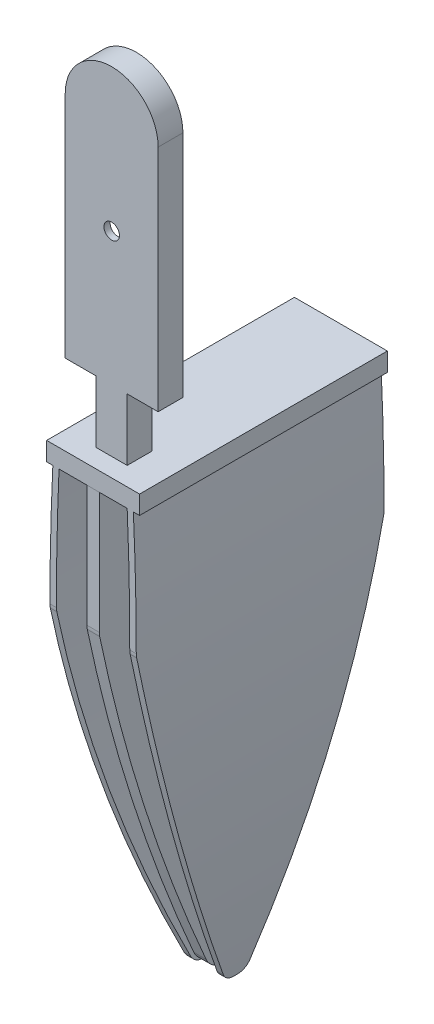
from build123d import *

# Parameters (mm, degrees)
EXTRUDE_1_DEPTH          = 2
EXTRUDE_1_DEPTH_BACK     = 2
EXTRUDE_2_DEPTH          = 7.5
EXTRUDE_2_DEPTH_BACK     = 7.5
EXTRUDE_4_DEPTH          = 1
EXTRUDE_4_DEPTH_BACK     = 1
EXTRUDE_8_DEPTH          = 23
EXTRUDE_8_DEPTH_BACK     = 17
SKETCH_21_W              = 5
SKETCH_21_H              = 10
CUT_EXTRUDE_4_DEPTH      = 4
CUT_EXTRUDE_5_DEPTH      = 1
CUT_EXTRUDE_5_DEPTH_BACK = 2
SKETCH_23_R              = 1.25
CUT_EXTRUDE_6_DEPTH      = 13
FILLET_11_R              = 3
FILLET_12_R              = 3
FILLET_13_R              = 3
CUT_EXTRUDE_7_DEPTH      = 10
CUT_EXTRUDE_7_DEPTH_BACK = 10
FILLET_17_R              = 2
FILLET_18_R              = 2
FILLET_19_R              = 2
FILLET_20_R              = 2
FILLET_21_R              = 3
FILLET_22_R              = 3
FILLET_23_R              = 3
FILLET_24_R              = 3


with BuildPart() as part:
    # 草圖1 → 填料-伸長1 (new, two sides: drawn at the far end of the back side and taken through both)
    with BuildSketch(Plane.XY.offset(-EXTRUDE_1_DEPTH_BACK)):
        with BuildLine():
            Line((7.5, 8), (7.5, 55))
            ThreePointArc((7.5, 55), (0, 62.5), (-7.5, 55))
            Line((-7.5, 55), (-7.5, 8))
            Line((-7.5, 8), (7.5, 8))
        make_face()
    extrude(amount=EXTRUDE_1_DEPTH + EXTRUDE_1_DEPTH_BACK)

    # 草圖6 → 填料-伸長2 (add, two sides: drawn at the far end of the back side and taken through both)
    with BuildSketch(Plane(origin=(0, 0, 0), x_dir=(0, 0, -1), z_dir=(1, 0, 0)).offset(-EXTRUDE_2_DEPTH_BACK)):
        Polygon((-2, 8), (-5, 8), (-5, 5), (-2, 5), (35, 5), (35, 8), align=None)
    extrude(amount=EXTRUDE_2_DEPTH + EXTRUDE_2_DEPTH_BACK)

    # 草圖19 → 填料-伸長8 (add, two sides: drawn at the far end of the back side and taken through both)
    with BuildSketch(Plane.XY.offset(-18).offset(-EXTRUDE_8_DEPTH_BACK)):
        with BuildLine():
            Line((6.5, 5), (5.5, 5))
            ThreePointArc((5.5, 5), (5.47282517, -33.328822067), (2, -71.5))
            Line((2, -71.5), (3, -71.5))
            ThreePointArc((3, -71.5), (6.537897336, -33.331799225), (6.5, 5))
        make_face()
        with BuildLine():
            Line((-3, -71.5), (-2, -71.5))
            ThreePointArc((-2, -71.5), (-5.47282517, -33.328822067), (-5.5, 5))
            Line((-5.5, 5), (-6.5, 5))
            ThreePointArc((-6.5, 5), (-6.537897336, -33.331799225), (-3, -71.5))
        make_face()
    extrude(amount=EXTRUDE_8_DEPTH + EXTRUDE_8_DEPTH_BACK)

    # 草圖21 → 除料-伸長4 (cut)
    with BuildSketch(Plane.XY.offset(2)):
        with Locations((-5, 13)):
            Rectangle(SKETCH_21_W, SKETCH_21_H)
        with Locations((5, 13)):
            Rectangle(SKETCH_21_W, SKETCH_21_H)
    extrude(amount=-CUT_EXTRUDE_4_DEPTH, mode=Mode.SUBTRACT)

    # 草圖3 → 除料-伸長5 (cut, two sides: drawn at the far end of the back side and taken through both)
    with BuildSketch(Plane.XY.offset(-CUT_EXTRUDE_5_DEPTH_BACK)):
        with BuildLine():
            Line((-2.106194146, 57.35480611), (-4.932538983, 40.323847539))
            ThreePointArc((-4.932538983, 40.323847539), (-5, 39.50527611), (-4.932538983, 38.686704682))
            Line((-4.932538983, 38.686704682), (-2.106194146, 21.65574611))
            ThreePointArc((-2.106194146, 21.65574611), (0, 19.87027611), (2.106194146, 21.65574611))
            Line((2.106194146, 21.65574611), (4.932538983, 38.686704682))
            ThreePointArc((4.932538983, 38.686704682), (5, 39.50527611), (4.932538983, 40.323847539))
            Line((4.932538983, 40.323847539), (2.106194146, 57.35480611))
            ThreePointArc((2.106194146, 57.35480611), (0, 59.14027611), (-2.106194146, 57.35480611))
        make_face()
    extrude(amount=CUT_EXTRUDE_5_DEPTH + CUT_EXTRUDE_5_DEPTH_BACK, mode=Mode.SUBTRACT)

    # 草圖23 → 除料-伸長6 (cut)
    with BuildSketch(Plane(origin=(0, 0, -2), x_dir=(-1, 0, 0), z_dir=(0, 0, -1))):
        with Locations((0, 39.50527611)):
            Circle(SKETCH_23_R)
    extrude(amount=-CUT_EXTRUDE_6_DEPTH, mode=Mode.SUBTRACT)

    # 草圖20 → 除料-伸長7 (cut, two sides: drawn at the far end of the back side and taken through both)
    with BuildSketch(Plane(origin=(0, 0, 0), x_dir=(0, 0, -1), z_dir=(1, 0, 0)).offset(-CUT_EXTRUDE_7_DEPTH_BACK)):
        with BuildLine():
            ThreePointArc((15, -75), (3.242716215, -45.534786617), (-5, -14.9))
            Line((-5, -14.9), (-5, -75))
            Line((-5, -75), (15, -75))
        make_face()
        with BuildLine():
            ThreePointArc((35, -14.9), (26.757283785, -45.534786617), (15, -75))
            Line((15, -75), (35, -75))
            Line((35, -75), (35, -14.9))
        make_face()
    extrude(amount=CUT_EXTRUDE_7_DEPTH + CUT_EXTRUDE_7_DEPTH_BACK, mode=Mode.SUBTRACT)

    # 圓角17
    fillet_17_edges = [part.edges().sort_by_distance(p)[0] for p in [
        (2.5, -71.5, -16.609354803),
    ]]
    fillet(fillet_17_edges, radius=FILLET_17_R)

    # 圓角18
    fillet_18_edges = [part.edges().sort_by_distance(p)[0] for p in [
        (2.5, -71.5, -13.390645197),
    ]]
    fillet(fillet_18_edges, radius=FILLET_18_R)

    # 圓角19
    fillet_19_edges = [part.edges().sort_by_distance(p)[0] for p in [
        (-2.5, -71.5, -16.609354803),
    ]]
    fillet(fillet_19_edges, radius=FILLET_19_R)

    # 圓角20
    fillet_20_edges = [part.edges().sort_by_distance(p)[0] for p in [
        (-2.5, -71.5, -13.390645197),
    ]]
    fillet(fillet_20_edges, radius=FILLET_20_R)

    # 圓角21
    fillet_21_edges = [part.edges().sort_by_distance(p)[0] for p in [
        (-6.441667624, -14.9, 5),
    ]]
    fillet(fillet_21_edges, radius=FILLET_21_R)

    # 圓角22
    fillet_22_edges = [part.edges().sort_by_distance(p)[0] for p in [
        (6.441667624, -14.9, 5),
    ]]
    fillet(fillet_22_edges, radius=FILLET_22_R)

    # 圓角23
    fillet_23_edges = [part.edges().sort_by_distance(p)[0] for p in [
        (-6.441667624, -14.9, -35),
    ]]
    fillet(fillet_23_edges, radius=FILLET_23_R)

    # 圓角24
    fillet_24_edges = [part.edges().sort_by_distance(p)[0] for p in [
        (6.441667624, -14.9, -35),
    ]]
    fillet(fillet_24_edges, radius=FILLET_24_R)


with BuildPart() as body_2:
    # 草圖8 → 填料-伸長4 (new, two sides: drawn at the far end of the back side and taken through both)
    with BuildSketch(Plane(origin=(0, 0, 0), x_dir=(0, 0, -1), z_dir=(1, 0, 0)).offset(-EXTRUDE_4_DEPTH_BACK)):
        with BuildLine():
            Line((35, 5), (35, -14.9))
            ThreePointArc((35, -14.9), (26.757283785, -45.534786617), (15, -75))
            ThreePointArc((15, -75), (3.242716215, -45.534786617), (-5, -14.9))
            Line((-5, -14.9), (-5, 5))
            Line((-5, 5), (35, 5))
        make_face()
    extrude(amount=EXTRUDE_4_DEPTH + EXTRUDE_4_DEPTH_BACK)

    # 圓角11
    fillet_11_edges = [body_2.edges().sort_by_distance(p)[0] for p in [
        (0, -75, -15),
    ]]
    fillet(fillet_11_edges, radius=FILLET_11_R)

    # 圓角12
    fillet_12_edges = [body_2.edges().sort_by_distance(p)[0] for p in [
        (0, -14.9, 5),
    ]]
    fillet(fillet_12_edges, radius=FILLET_12_R)

    # 圓角13
    fillet_13_edges = [body_2.edges().sort_by_distance(p)[0] for p in [
        (0, -14.9, -35),
    ]]
    fillet(fillet_13_edges, radius=FILLET_13_R)


solid = Compound([part.part, body_2.part])
